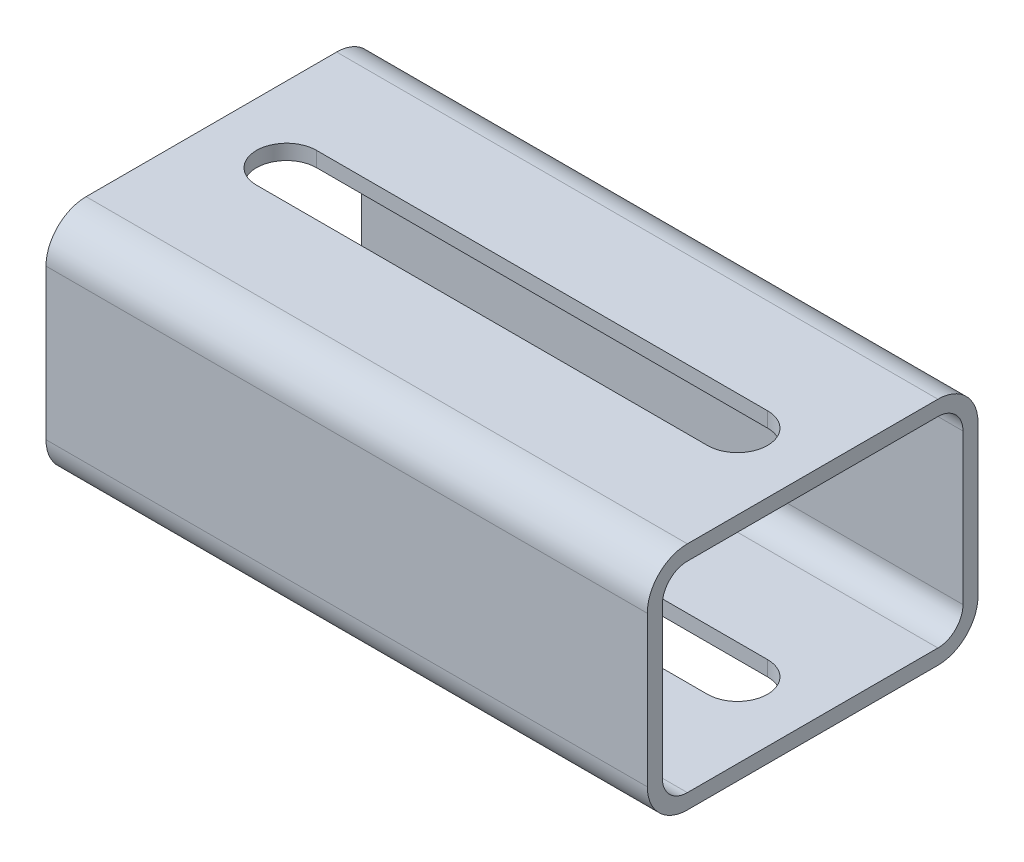
from build123d import *

# Parameters (mm, degrees)
EXTRUDE_THIN1_DEPTH = 60
CUT_EXTRUDE1_DEPTH  = 47


with BuildPart() as part:
    # Sketch1 → Extrude-Thin1 (new body, symmetric)
    with BuildSketch(Plane(origin=(0, 0, 0), x_dir=(0, 0, -1), z_dir=(1, 0, 0))):
        with BuildLine():
            Line((-25, 23), (25, 23))
            ThreePointArc((25, 23), (30.656854249, 20.656854249), (33, 15))
            Line((33, 15), (33, -15))
            ThreePointArc((33, -15), (30.656854249, -20.656854249), (25, -23))
            Line((25, -23), (-25, -23))
            ThreePointArc((-25, -23), (-30.656854249, -20.656854249), (-33, -15))
            Line((-33, -15), (-33, 15))
            ThreePointArc((-33, 15), (-30.656854249, 20.656854249), (-25, 23))
        make_face()
        with BuildLine():
            Line((-25, 20), (25, 20))
            ThreePointArc((25, 20), (28.535533906, 18.535533906), (30, 15))
            Line((30, 15), (30, -15))
            ThreePointArc((30, -15), (28.535533906, -18.535533906), (25, -20))
            Line((25, -20), (-25, -20))
            ThreePointArc((-25, -20), (-28.535533906, -18.535533906), (-30, -15))
            Line((-30, -15), (-30, 15))
            ThreePointArc((-30, 15), (-28.535533906, 18.535533906), (-25, 20))
        make_face(mode=Mode.SUBTRACT)
    extrude(amount=EXTRUDE_THIN1_DEPTH, both=True)

    # Sketch2 → Cut-Extrude1 (cut, through all)
    with BuildSketch(Plane(origin=(0, 23, 0), x_dir=(1, 0, 0), z_dir=(0, 1, 0))):
        with BuildLine():
            Line((-45, 6), (45, 6))
            ThreePointArc((45, 6), (51, 0), (45, -6))
            Line((45, -6), (-45, -6))
            ThreePointArc((-45, -6), (-51, 0), (-45, 6))
        make_face()
    extrude(amount=-CUT_EXTRUDE1_DEPTH, mode=Mode.SUBTRACT)


solid = part.part
